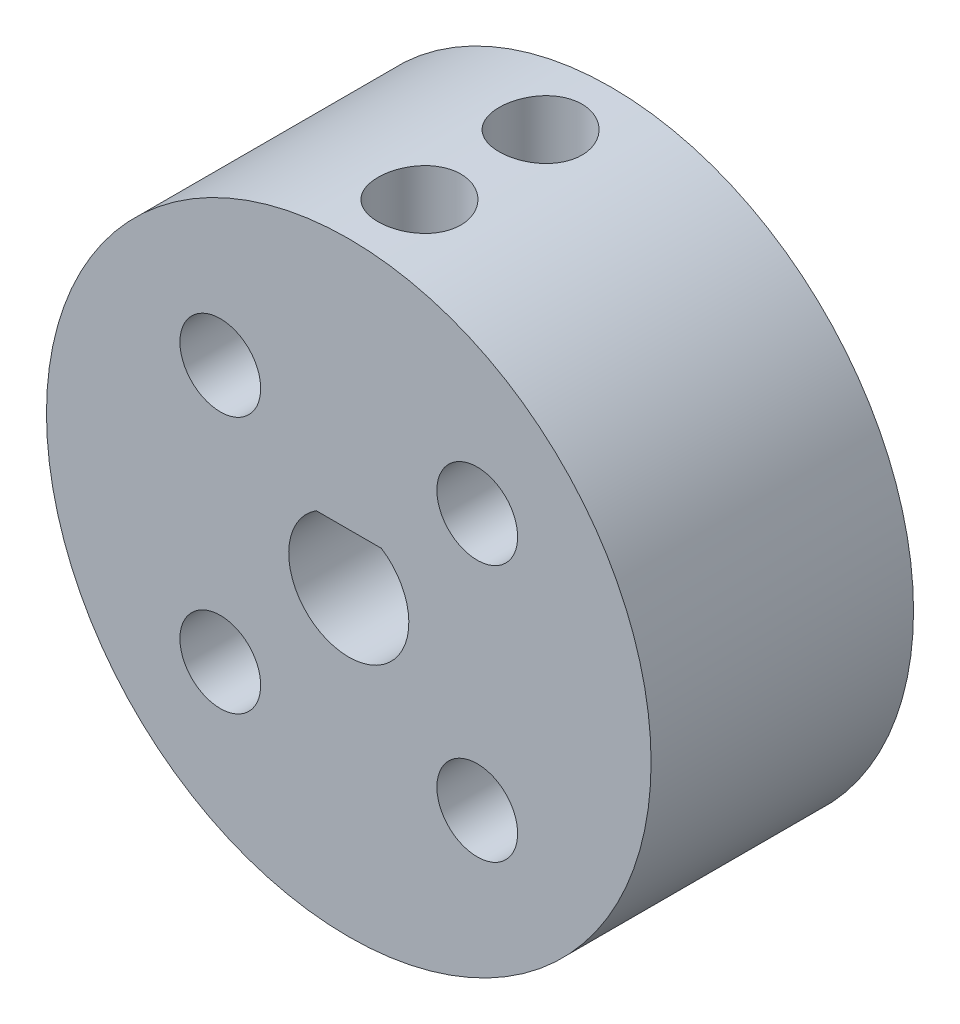
from build123d import *

# Parameters (mm, degrees)
SKETCH1_R           = 14.975
BOSS_EXTRUDE1_DEPTH = 13
SKETCH3_R           = 2.05
CUT_EXTRUDE2_DEPTH  = 16
CUT_EXTRUDE7_DEPTH  = 5
SKETCH12_R          = 2
CUT_EXTRUDE8_DEPTH  = 9.0000001
SKETCH13_R          = 2.975
CUT_EXTRUDE9_DEPTH  = 1


with BuildPart() as part:
    # Sketch1 → Boss-Extrude1 (new body)
    with BuildSketch(Plane.XY):
        Circle(SKETCH1_R)
        with BuildLine():
            Line((1.612645342, 2.5), (-1.612645342, 2.5))
            ThreePointArc((-1.612645342, 2.5), (0, -2.975), (1.612645342, 2.5))
        make_face(mode=Mode.SUBTRACT)
    extrude(amount=BOSS_EXTRUDE1_DEPTH)

    # Sketch3 → Cut-Extrude2 (cut)
    with BuildSketch(Plane(origin=(0, 0, 0), x_dir=(1, 0, 0), z_dir=(0, 1, 0))):
        with Locations((0, -3.5)):
            Circle(SKETCH3_R)
        with Locations((0, -9.5)):
            Circle(SKETCH3_R)
    extrude(amount=CUT_EXTRUDE2_DEPTH, mode=Mode.SUBTRACT)

    # Sketch11 → Cut-Extrude7 (cut)
    with BuildSketch(Plane(origin=(0, 0, 0), x_dir=(-1, 0, 0), z_dir=(0, 0, -1))):
        Polygon((-6.363961031, 2.380244173), (-2.913961031, 4.372102602), (-2.913961031, 8.355819459), (-6.363961031, 10.347677888), (-9.813961031, 8.355819459), (-9.813961031, 4.372102602), align=None)
        Polygon((9.813961031, 8.355819459), (6.363961031, 10.347677888), (2.913961031, 8.355819459), (2.913961031, 4.372102602), (6.363961031, 2.380244173), (9.813961031, 4.372102602), align=None)
        Polygon((9.813961031, -4.372102602), (9.813961031, -8.355819459), (6.363961031, -10.347677888), (2.913961031, -8.355819459), (2.913961031, -4.372102602), (6.363961031, -2.380244173), align=None)
        Polygon((-9.813961031, -4.372102602), (-6.363961031, -2.380244173), (-2.913961031, -4.372102602), (-2.913961031, -8.355819459), (-6.363961031, -10.347677888), (-9.813961031, -8.355819459), align=None)
    extrude(amount=-CUT_EXTRUDE7_DEPTH, mode=Mode.SUBTRACT)

    # Sketch12 → Cut-Extrude8 (cut, through all)
    with BuildSketch(Plane(origin=(0, 0, 5), x_dir=(-1, 0, 0), z_dir=(0, 0, -1))):
        with Locations((-6.363961031, 6.363961031)):
            Circle(SKETCH12_R)
        with Locations((6.363961031, 6.363961031)):
            Circle(SKETCH12_R)
        with Locations((6.363961031, -6.363961031)):
            Circle(SKETCH12_R)
        with Locations((-6.363961031, -6.363961031)):
            Circle(SKETCH12_R)
    extrude(amount=-CUT_EXTRUDE8_DEPTH, mode=Mode.SUBTRACT)

    # Sketch13 → Cut-Extrude9 (cut)
    with BuildSketch(Plane(origin=(0, 0, 0), x_dir=(-1, 0, 0), z_dir=(0, 0, -1))):
        Circle(SKETCH13_R)
    extrude(amount=-CUT_EXTRUDE9_DEPTH, mode=Mode.SUBTRACT)


solid = part.part
